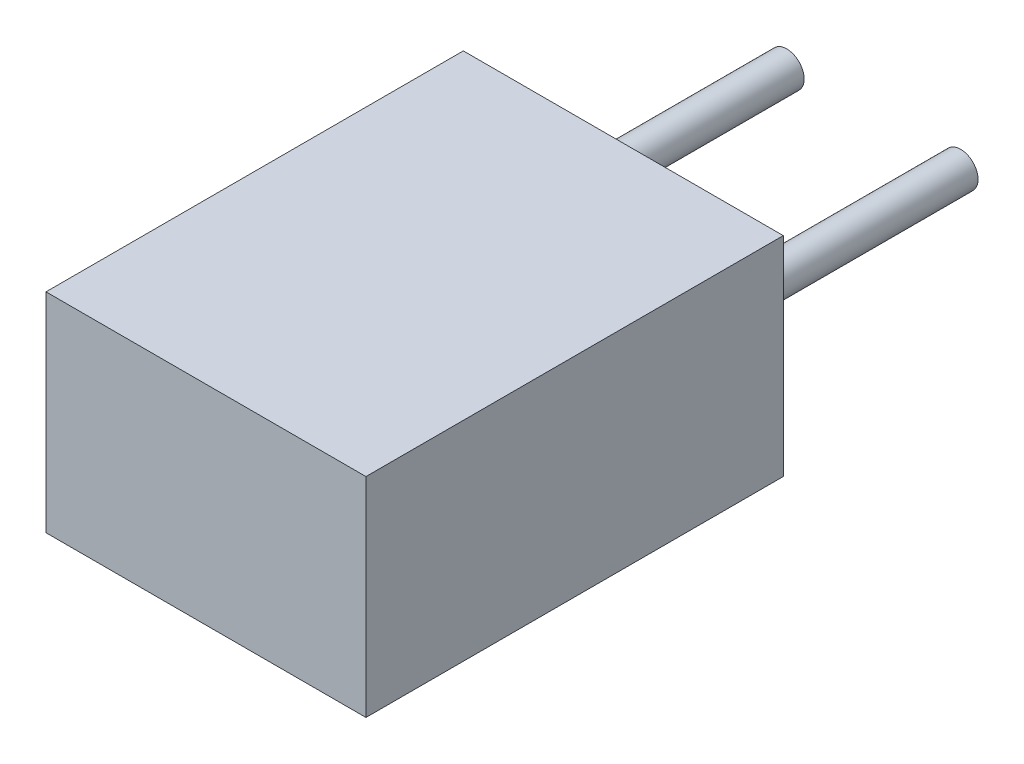
from build123d import *

# Parameters (mm, degrees)
ESQUISSE1_W        = 4.6
ESQUISSE1_H        = 3
BOSS_EXTRU_1_DEPTH = 6
ESQUISSE2_R        = 0.25
BOSS_EXTRU_2_DEPTH = 3.6


with BuildPart() as part:
    # Esquisse1 → Boss.-Extru.1 (new body)
    with BuildSketch(Plane.XY):
        Rectangle(ESQUISSE1_W, ESQUISSE1_H)
    extrude(amount=BOSS_EXTRU_1_DEPTH)

    # Esquisse2 → Boss.-Extru.2 (add)
    with BuildSketch(Plane(origin=(0, 0, 0), x_dir=(-1, 0, 0), z_dir=(0, 0, -1))):
        with Locations((-1.25, 0)):
            Circle(ESQUISSE2_R)
        with Locations((1.25, 0)):
            Circle(ESQUISSE2_R)
    extrude(amount=BOSS_EXTRU_2_DEPTH)


solid = part.part
